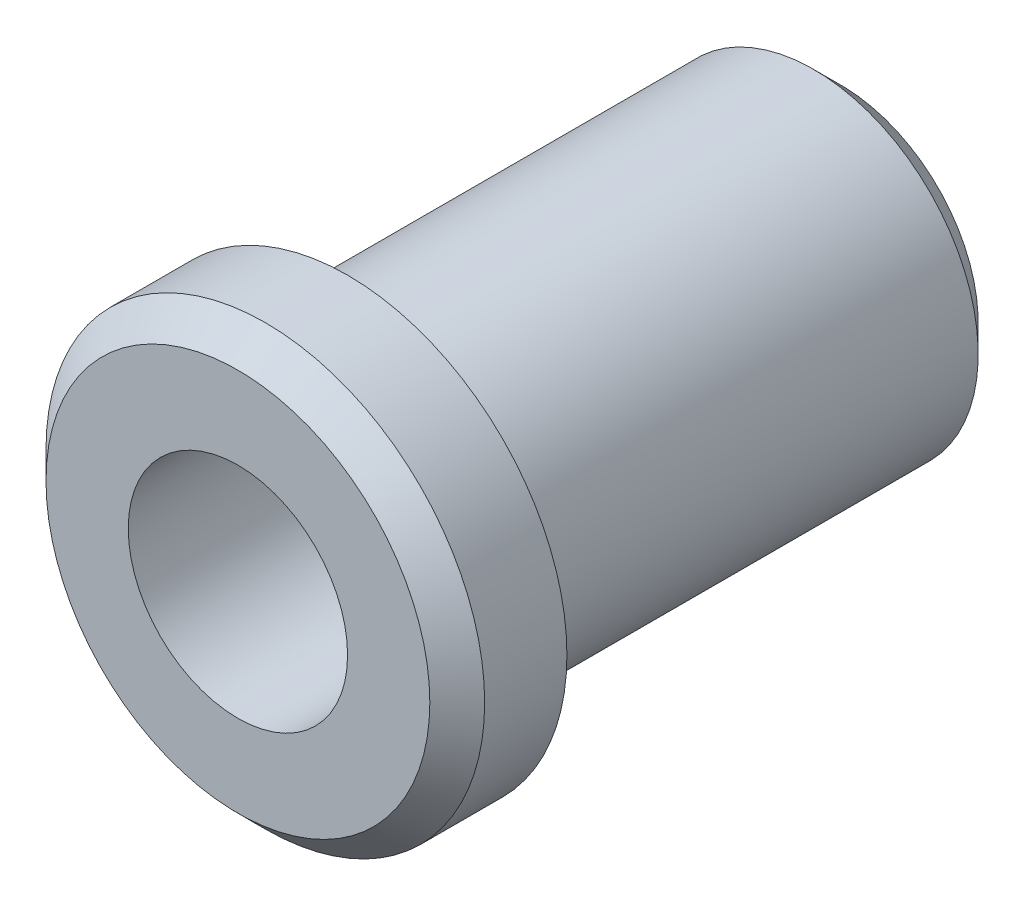
from build123d import *

# Parameters (mm, degrees)
SKETCH_1_R          = 8
EXTRUDE_1_DEPTH     = 4
SKETCH_2_R          = 6
EXTRUDE_2_DEPTH     = 18
SKETCH_3_R          = 4
CUT_EXTRUDE_1_DEPTH = 23
CHAMFER_1_SIZE      = 1


with BuildPart() as part:
    # 스케치1 → 보스-돌출1 (new body)
    with BuildSketch(Plane.XY):
        Circle(SKETCH_1_R)
    extrude(amount=EXTRUDE_1_DEPTH)

    # 스케치2 → 보스-돌출2 (add)
    with BuildSketch(Plane(origin=(0, 0, 0), x_dir=(-1, 0, 0), z_dir=(0, 0, -1))):
        Circle(SKETCH_2_R)
    extrude(amount=EXTRUDE_2_DEPTH)

    # 스케치3 → 컷-돌출1 (cut, through all)
    with BuildSketch(Plane(origin=(0, 0, -18), x_dir=(-1, 0, 0), z_dir=(0, 0, -1))):
        Circle(SKETCH_3_R)
    extrude(amount=-CUT_EXTRUDE_1_DEPTH, mode=Mode.SUBTRACT)

    # 모따기1
    chamfer_1_edges = [part.edges().sort_by_distance(p)[0] for p in [
        (-8, 0, 4),
        (6, 0, -18),
    ]]
    chamfer(chamfer_1_edges, length=CHAMFER_1_SIZE)


solid = part.part
